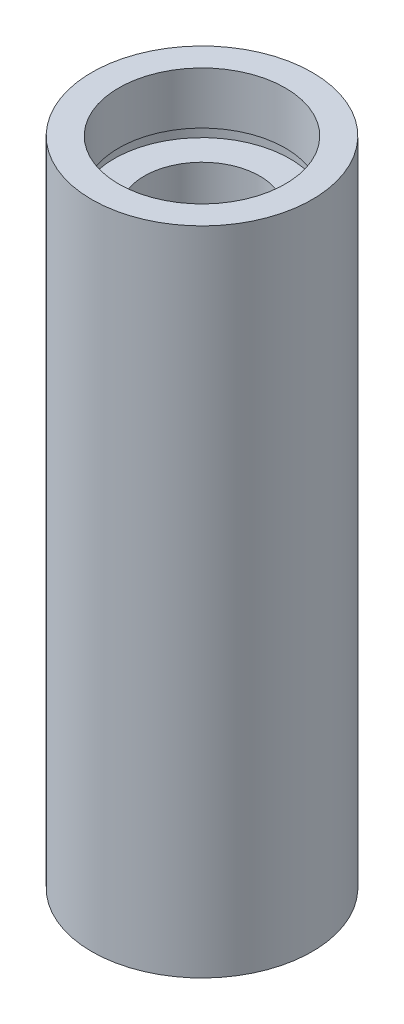
from build123d import *


with BuildPart() as part:
    # 草图1 → 旋转1 (revolve)
    with BuildSketch(Plane.XY, mode=Mode.PRIVATE) as revolve_1_sk:
        Polygon((7, 0), (7, 4.5), (7.6, 4.5), (7.6, 5.5), (5, 5.5), (5, 50.8), (7.6, 50.8), (7.6, 51.8), (7.2, 51.8), (7.2, 56.3), (9.525, 56.3), (9.525, 0), align=None)
    revolve(revolve_1_sk.sketch.rotate(Axis((0, 161.376166943, 0), (0, -1, 0)), 90), axis=Axis((0, 161.376166943, 0), (0, -1, 0)))  # turned: the seam where the file's is


solid = part.part
